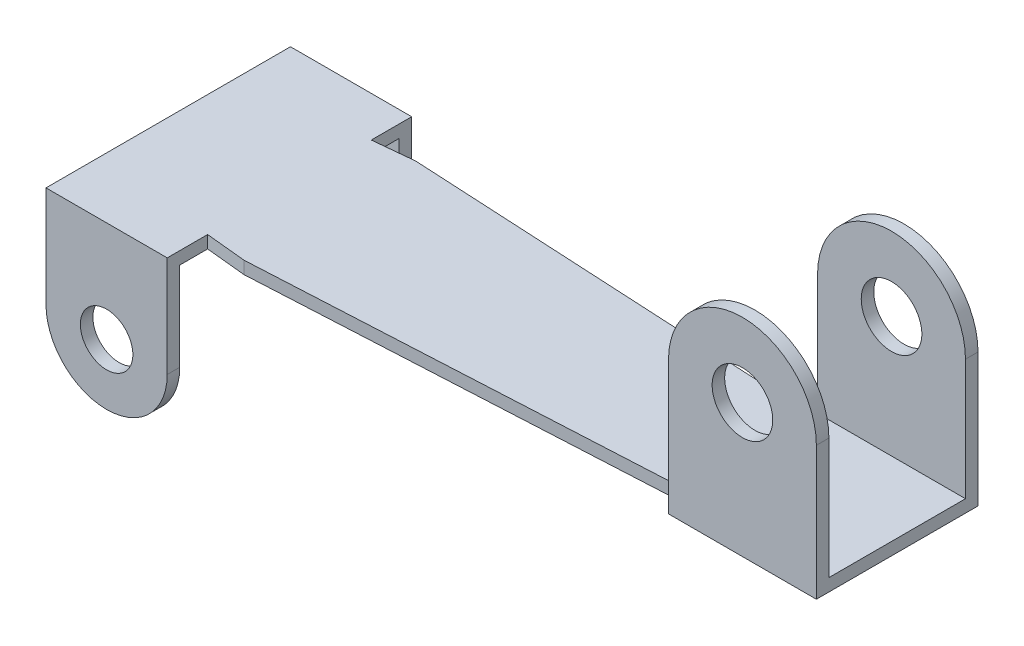
from build123d import *

# Parameters (mm, degrees)
BOSS_EXTRUDE1_DEPTH = 0.31
SKETCH2_W           = 3
SKETCH2_H           = 0.31
BOSS_EXTRUDE2_DEPTH = 4
SKETCH3_R           = 0.65
CUT_EXTRUDE1_DEPTH  = 11
SKETCH4_W           = 3.66
SKETCH4_H           = 0.31
BOSS_EXTRUDE3_DEPTH = 4.82
SKETCH5_R           = 0.75
CUT_EXTRUDE2_DEPTH  = 4.82


with BuildPart() as part:
    # Sketch1 → Boss-Extrude1 (new body)
    with BuildSketch(Plane(origin=(0, 0, 0), x_dir=(1, 0, 0), z_dir=(0, 1, 0))):
        Polygon((0, 3.025), (0, -3.025), (3, -3.025), (3, -2.025), (4, -2.125), (14.38, -1.575), (14.38, -2), (18.04, -2), (18.04, 2), (14.38, 2), (14.38, 1.575), (4, 2.125), (3, 2.025), (3, 3.025), align=None)
    extrude(amount=BOSS_EXTRUDE1_DEPTH)

    # Sketch2 → Boss-Extrude2 (add)
    with BuildSketch(Plane(origin=(0, 0.31, 0), x_dir=(1, 0, 0), z_dir=(0, 1, 0))):
        with Locations((1.5, 2.87)):
            Rectangle(SKETCH2_W, SKETCH2_H)
        with Locations((1.5, -2.87)):
            Rectangle(SKETCH2_W, SKETCH2_H)
    extrude(amount=-BOSS_EXTRUDE2_DEPTH)

    # Sketch3 → Cut-Extrude1 (cut)
    with BuildSketch(Plane.XY.offset(3.025)):
        with Locations((1.5, -2.19)):
            Circle(SKETCH3_R)
        with BuildLine():
            ThreePointArc((3, -2.19), (2.560660172, -3.250660172), (1.5, -3.69))
            Line((1.5, -3.69), (3, -3.69))
            Line((3, -3.69), (3, -2.19))
        make_face()
        with BuildLine():
            ThreePointArc((1.5, -3.69), (0.439339828, -3.250660172), (0, -2.19))
            Line((0, -2.19), (0, -3.69))
            Line((0, -3.69), (1.5, -3.69))
        make_face()
    extrude(amount=-CUT_EXTRUDE1_DEPTH, mode=Mode.SUBTRACT)

    # Sketch4 → Boss-Extrude3 (add)
    with BuildSketch(Plane(origin=(0, 0.31, 0), x_dir=(1, 0, 0), z_dir=(0, 1, 0))):
        with Locations((16.21, 1.845)):
            Rectangle(SKETCH4_W, SKETCH4_H)
        with Locations((16.21, -1.845)):
            Rectangle(SKETCH4_W, SKETCH4_H)
    extrude(amount=BOSS_EXTRUDE3_DEPTH)

    # Sketch5 → Cut-Extrude2 (cut)
    with BuildSketch(Plane(origin=(0, 0, -2), x_dir=(-1, 0, 0), z_dir=(0, 0, -1))):
        with BuildLine():
            Line((-18.04, 5.13), (-18.04, 3.3))
            ThreePointArc((-18.04, 3.3), (-17.50400541, 4.59400541), (-16.21, 5.13))
            Line((-16.21, 5.13), (-18.04, 5.13))
        make_face()
        with BuildLine():
            Line((-14.38, 5.13), (-16.21, 5.13))
            ThreePointArc((-16.21, 5.13), (-14.91599459, 4.59400541), (-14.38, 3.3))
            Line((-14.38, 3.3), (-14.38, 5.13))
        make_face()
        with Locations((-16.21, 3.3)):
            Circle(SKETCH5_R)
    extrude(amount=-CUT_EXTRUDE2_DEPTH, mode=Mode.SUBTRACT)


solid = part.part
